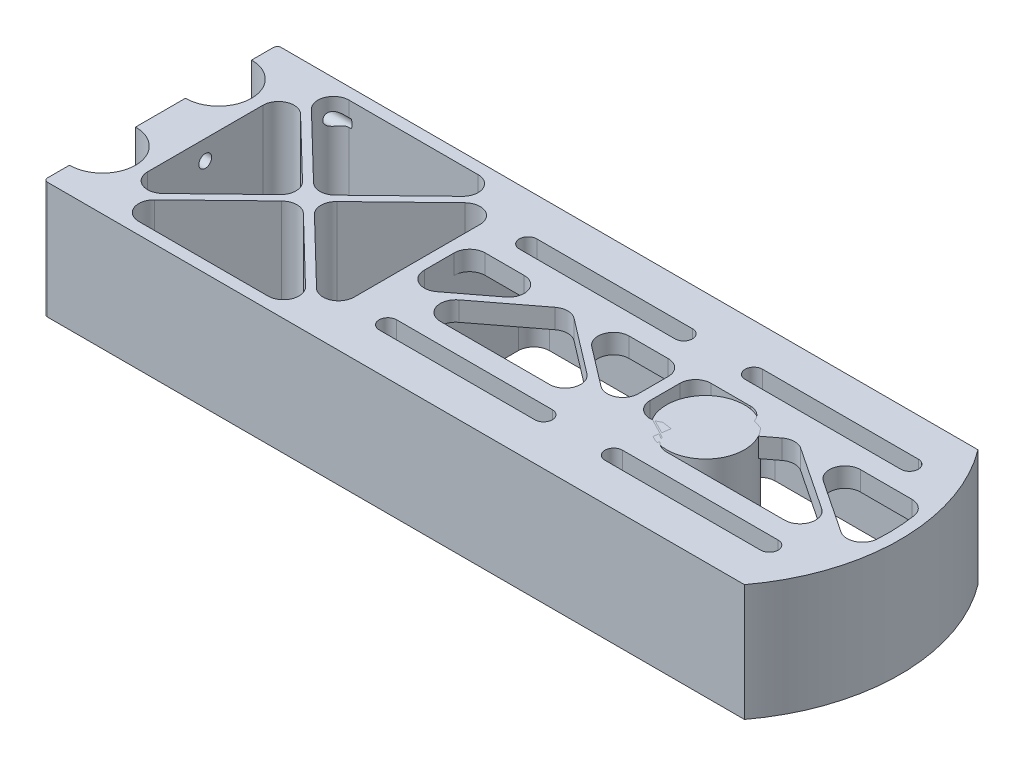
from build123d import *

# Parameters (mm, degrees)
EXTRUDE_1_DEPTH      = 30
CUT_EXTRUDE_1_DEPTH  = 31
TEMP_R               = 10
EXTRUDE_2_DEPTH      = 30
EXTRUDE_3_DEPTH      = 5
EXTRUDE_4_DEPTH      = 30
SKETCH_6_W           = 3
SKETCH_6_H           = 54
EXTRUDE_5_DEPTH      = 30
EXTRUDE_6_DEPTH      = 30
SKETCH_9_W           = 3
SKETCH_9_H           = 54
EXTRUDE_8_DEPTH      = 25
EXTRUDE_8_DEPTH_BACK = 5
EXTRUDE_7_DEPTH      = 5
FILLET_1_R           = 4
FILLET_2_R           = 4
FILLET_3_R           = 4
EXTRUDE_9_DEPTH      = 5
CUT_EXTRUDE_4_DEPTH  = 31
EXTRUDE_10_DEPTH     = 30
FILLET_4_R           = 4
M4X0_71_AT_2_COUNT   = 2
M4X0_71_AT_2_PITCH   = 25.75
M4X0_71_AT_3_COUNT   = 2
M4X0_71_AT_3_PITCH   = 51.5
M4X0_71_AT_4_COUNT   = 2
M4X0_71_AT_4_PITCH   = 55.247171873
M4X0_71_AT_5_COUNT   = 2
M4X0_71_AT_5_PITCH   = 32.60463924
M4X0_71_AT_6_COUNT   = 2
M4X0_71_AT_6_PITCH   = 20
FILLET_5_R           = 1


with BuildPart() as part:
    # Эскиз1 → Бобышка-Вытянуть1 (new body)
    with BuildSketch(Plane(origin=(0, 0, 0), x_dir=(1, 0, 0), z_dir=(0, 1, 0))):
        with BuildLine():
            Line((0, 60), (180, 60))
            ThreePointArc((180, 60), (190, 30), (180, 0))
            Line((180, 0), (0, 0))
            Line((0, 0), (0, 8))
            ThreePointArc((0, 8), (7.1, 15.1), (0, 22.2))
            Line((0, 22.2), (0, 37.8))
            ThreePointArc((0, 37.8), (7.1, 44.9), (0, 52))
            Line((0, 52), (0, 60))
        make_face()
    extrude(amount=EXTRUDE_1_DEPTH)

    # Эскиз2 → Вырез-Вытянуть1 (cut, through all)
    with BuildSketch(Plane(origin=(0, 30, 0), x_dir=(1, 0, 0), z_dir=(0, 1, 0))):
        with BuildLine():
            Line((3, 3), (178.470768123, 3))
            ThreePointArc((178.470768123, 3), (187, 30), (178.470768123, 57))
            Line((178.470768123, 57), (3, 57))
            Line((3, 57), (3, 54.544169223))
            ThreePointArc((3, 54.544169223), (10.1, 44.9), (3, 35.255830777))
            Line((3, 35.255830777), (3, 24.744169223))
            ThreePointArc((3, 24.744169223), (10.1, 15.1), (3, 5.455830777))
            Line((3, 5.455830777), (3, 3))
        make_face()
    extrude(amount=-CUT_EXTRUDE_1_DEPTH, mode=Mode.SUBTRACT)

    # Эскиз3 → Бобышка-Вытянуть3 (add)
    with BuildSketch(Plane(origin=(0, 30, 0), x_dir=(1, 0, 0), z_dir=(0, 1, 0))):
        with BuildLine():
            Line((178.470768123, 57), (68.916586692, 57))
            Line((68.916586692, 57), (68.916586692, 40.5))
            Line((68.916586692, 40.5), (185.812116301, 40.5))
            ThreePointArc((185.812116301, 40.5), (182.941397878, 49.105924428), (178.470768123, 57))
        make_face()
        with BuildLine():
            Line((116.416586692, 43.5), (76.416586692, 43.5))
            ThreePointArc((76.416586692, 43.5), (71.916586692, 48), (76.416586692, 52.5))
            Line((76.416586692, 52.5), (116.416586692, 52.5))
            ThreePointArc((116.416586692, 52.5), (120.916586692, 48), (116.416586692, 43.5))
        make_face(mode=Mode.SUBTRACT)
        with BuildLine():
            ThreePointArc((174.416586692, 52.5), (178.916586692, 48), (174.416586692, 43.5))
            Line((174.416586692, 43.5), (134.416586692, 43.5))
            ThreePointArc((134.416586692, 43.5), (129.916586692, 48), (134.416586692, 52.5))
            Line((134.416586692, 52.5), (174.416586692, 52.5))
        make_face(mode=Mode.SUBTRACT)
        with BuildLine():
            ThreePointArc((178.470768123, 3), (182.941397878, 10.894075572), (185.812116301, 19.5))
            Line((185.812116301, 19.5), (68.916586692, 19.5))
            Line((68.916586692, 19.5), (68.916586692, 3))
            Line((68.916586692, 3), (178.470768123, 3))
        make_face()
        with BuildLine():
            ThreePointArc((76.416586692, 7.5), (71.916586692, 12), (76.416586692, 16.5))
            Line((76.416586692, 16.5), (116.416586692, 16.5))
            ThreePointArc((116.416586692, 16.5), (120.916586692, 12), (116.416586692, 7.5))
            Line((116.416586692, 7.5), (76.416586692, 7.5))
        make_face(mode=Mode.SUBTRACT)
        with BuildLine():
            Line((134.416586692, 16.5), (174.416586692, 16.5))
            ThreePointArc((174.416586692, 16.5), (178.916586692, 12), (174.416586692, 7.5))
            Line((174.416586692, 7.5), (134.416586692, 7.5))
            ThreePointArc((134.416586692, 7.5), (129.916586692, 12), (134.416586692, 16.5))
        make_face(mode=Mode.SUBTRACT)
    extrude(amount=-EXTRUDE_3_DEPTH)

    # Эскиз4 → Бобышка-Вытянуть4 (add, through all)
    with BuildSketch(Plane(origin=(0, 30, 0), x_dir=(1, 0, 0), z_dir=(0, 1, 0))):
        with BuildLine():
            Line((10.1, 57), (3, 57))
            Line((3, 57), (3, 54.544169223))
            ThreePointArc((3, 54.544169223), (8.133572401, 50.887904475), (10.1, 44.9))
            Line((10.1, 44.9), (10.1, 57))
        make_face()
        with BuildLine():
            Line((10.1, 15.099999916), (10.1, 44.9))
            ThreePointArc((10.1, 44.9), (8.133572401, 38.912095525), (3, 35.255830777))
            Line((3, 35.255830777), (3, 24.744169223))
            ThreePointArc((3, 24.744169223), (8.133572426, 21.087904441), (10.1, 15.099999916))
        make_face()
        with BuildLine():
            Line((10.1, 3), (10.1, 15.099999916))
            ThreePointArc((10.1, 15.099999916), (8.133572376, 9.112095491), (3, 5.455830777))
            Line((3, 5.455830777), (3, 3))
            Line((3, 3), (10.1, 3))
        make_face()
    extrude(amount=-EXTRUDE_4_DEPTH)

    # Эскиз6 → Бобышка-Вытянуть5 (add, through all)
    with BuildSketch(Plane(origin=(0, 30, 0), x_dir=(1, 0, 0), z_dir=(0, 1, 0))):
        with Locations((67.416586692, 30)):
            Rectangle(SKETCH_6_W, SKETCH_6_H)
    extrude(amount=-EXTRUDE_5_DEPTH)

    # Эскиз7 → Бобышка-Вытянуть6 (add, through all)
    with BuildSketch(Plane(origin=(0, 30, 0), x_dir=(1, 0, 0), z_dir=(0, 1, 0))):
        Polygon((10.1, 55.608609353), (36.57009563, 30), (10.1, 4.391390647), (10.1, 3), (11.538197716, 3), (38.008293346, 28.608609353), (64.478388976, 3), (65.916586692, 3), (65.916586692, 4.391390647), (39.446491062, 30), (65.916586692, 55.608609353), (65.916586692, 57), (64.478388976, 57), (38.008293346, 31.391390647), (11.538197716, 57), (10.1, 57), align=None)
    extrude(amount=-EXTRUDE_6_DEPTH)

    # Эскиз9 → Бобышка-Вытянуть8 (add, two sides)
    with BuildSketch(Plane.XZ.offset(-25)) as extrude_8_sk:
        with Locations((125.416586692, -30)):
            Rectangle(SKETCH_9_W, SKETCH_9_H)
    extrude(amount=EXTRUDE_8_DEPTH)
    extrude(extrude_8_sk.sketch, amount=-EXTRUDE_8_DEPTH_BACK)

    # Эскиз8 → Бобышка-Вытянуть7 (add)
    with BuildSketch(Plane(origin=(0, 30, 0), x_dir=(1, 0, 0), z_dir=(0, 1, 0))):
        Polygon((70.564267671, 19.5), (96.416586692, 39.241770889), (122.268905713, 19.5), (123.916586692, 19.5), (123.916586692, 20.758229111), (98.064267671, 40.5), (94.768905713, 40.5), (68.916586692, 20.758229111), (68.916586692, 19.5), align=None)
        with BuildLine():
            Line((128.569887735, 19.5), (154.477979009, 39.178204914))
            Line((154.477979009, 39.178204914), (184.008770478, 19.5))
            Line((184.008770478, 19.5), (185.812116301, 19.5))
            ThreePointArc((185.812116301, 19.5), (185.929117822, 20.024222532), (186.040120933, 20.549747915))
            Line((186.040120933, 20.549747915), (156.101072293, 40.5))
            Line((156.101072293, 40.5), (152.911636662, 40.5))
            Line((152.911636662, 40.5), (126.916586692, 20.755746568))
            Line((126.916586692, 20.755746568), (126.916586692, 19.5))
            Line((126.916586692, 19.5), (128.569887735, 19.5))
        make_face()
    extrude(amount=-EXTRUDE_7_DEPTH)

    # Скругление1
    fillet_1_edges = [part.edges().sort_by_distance(p)[0] for p in [
        (36.57009563, 15, -30),
        (11.538197716, 15, -57),
        (38.008293346, 15, -31.391390647),
        (64.478388976, 15, -57),
        (65.916586692, 15, -55.608609353),
        (39.446491062, 15, -30),
        (65.916586692, 15, -4.391390647),
        (64.478388976, 15, -3),
        (38.008293346, 15, -28.608609353),
        (11.538197716, 15, -3),
    ]]
    fillet(fillet_1_edges, radius=FILLET_1_R)

    # Скругление2
    fillet_2_edges = [part.edges().sort_by_distance(p)[0] for p in [
        (68.916586692, 12.5, -57),
        (68.916586692, 12.5, -3),
        (123.916586692, 12.5, -57),
        (126.916586692, 12.5, -3),
        (123.916586692, 12.5, -3),
        (126.916586692, 12.5, -57),
        (178.470768123, 12.5, -57),
        (178.470768123, 12.5, -3),
    ]]
    fillet(fillet_2_edges, radius=FILLET_2_R)

    # Скругление3
    fillet_3_edges = [part.edges().sort_by_distance(p)[0] for p in [
        (123.916586692, 27.5, -40.5),
        (126.916586692, 27.5, -40.5),
        (70.564267671, 27.5, -19.5),
        (68.916586692, 27.5, -20.758229111),
        (94.768905713, 27.5, -40.5),
        (98.064267671, 27.5, -40.5),
        (123.916586692, 27.5, -20.758229111),
        (122.268905713, 27.5, -19.5),
        (96.416586692, 27.5, -39.241770889),
        (128.569887735, 27.5, -19.5),
        (126.916586692, 27.5, -20.755746568),
        (152.911636662, 27.5, -40.5),
        (156.101072293, 27.5, -40.5),
        (186.040120933, 27.5, -20.549747915),
        (184.008770478, 27.5, -19.5),
        (154.477979009, 27.5, -39.178204914),
        (68.916586692, 27.5, -40.5),
        (185.812116301, 27.5, -40.5),
    ]]
    fillet(fillet_3_edges, radius=FILLET_3_R)

    # Эскиз10 → Бобышка-Вытянуть9 (add)
    with BuildSketch(Plane(origin=(0, 30, 0), x_dir=(1, 0, 0), z_dir=(0, 1, 0))):
        with BuildLine():
            Line((76.416586692, 52.5), (116.416586692, 52.5))
            ThreePointArc((116.416586692, 52.5), (120.916586692, 48), (116.416586692, 43.5))
            Line((116.416586692, 43.5), (76.416586692, 43.5))
            ThreePointArc((76.416586692, 43.5), (71.916586692, 48), (76.416586692, 52.5))
        make_face()
        with BuildLine():
            Line((116.416586692, 50.25), (76.416586692, 50.25))
            ThreePointArc((76.416586692, 50.25), (74.166586692, 48), (76.416586692, 45.75))
            Line((76.416586692, 45.75), (116.416586692, 45.75))
            ThreePointArc((116.416586692, 45.75), (118.666586692, 48), (116.416586692, 50.25))
        make_face(mode=Mode.SUBTRACT)
        with BuildLine():
            Line((174.416586692, 52.5), (134.416586692, 52.5))
            ThreePointArc((134.416586692, 52.5), (129.916586692, 48), (134.416586692, 43.5))
            Line((134.416586692, 43.5), (174.416586692, 43.5))
            ThreePointArc((174.416586692, 43.5), (178.916586692, 48), (174.416586692, 52.5))
        make_face()
        with BuildLine():
            Line((174.416586692, 45.75), (134.416586692, 45.75))
            ThreePointArc((134.416586692, 45.75), (132.166586692, 48), (134.416586692, 50.25))
            Line((134.416586692, 50.25), (174.416586692, 50.25))
            ThreePointArc((174.416586692, 50.25), (176.666586692, 48), (174.416586692, 45.75))
        make_face(mode=Mode.SUBTRACT)
        with BuildLine():
            Line((76.416586692, 16.5), (116.416586692, 16.5))
            ThreePointArc((116.416586692, 16.5), (120.916586692, 12), (116.416586692, 7.5))
            Line((116.416586692, 7.5), (76.416586692, 7.5))
            ThreePointArc((76.416586692, 7.5), (71.916586692, 12), (76.416586692, 16.5))
        make_face()
        with BuildLine():
            Line((76.416586692, 9.75), (116.416586692, 9.75))
            ThreePointArc((116.416586692, 9.75), (118.666586692, 12), (116.416586692, 14.25))
            Line((116.416586692, 14.25), (76.416586692, 14.25))
            ThreePointArc((76.416586692, 14.25), (74.166586692, 12), (76.416586692, 9.75))
        make_face(mode=Mode.SUBTRACT)
        with BuildLine():
            Line((174.416586692, 16.5), (134.416586692, 16.5))
            ThreePointArc((134.416586692, 16.5), (129.916586692, 12), (134.416586692, 7.5))
            Line((134.416586692, 7.5), (174.416586692, 7.5))
            ThreePointArc((174.416586692, 7.5), (178.916586692, 12), (174.416586692, 16.5))
        make_face()
        with BuildLine():
            Line((174.416586692, 14.25), (134.416586692, 14.25))
            ThreePointArc((134.416586692, 14.25), (132.166586692, 12), (134.416586692, 9.75))
            Line((134.416586692, 9.75), (174.416586692, 9.75))
            ThreePointArc((174.416586692, 9.75), (176.666586692, 12), (174.416586692, 14.25))
        make_face(mode=Mode.SUBTRACT)
    extrude(amount=-EXTRUDE_9_DEPTH)

    # Эскиз16 → Вырез-Вытянуть4 (cut, through all)
    with BuildSketch(Plane(origin=(0, 30, 0), x_dir=(1, 0, 0), z_dir=(0, 1, 0))):
        with BuildLine():
            Line((0, 8), (0, 6.6))
            ThreePointArc((0, 6.6), (8.5, 15.1), (0, 23.6))
            Line((0, 23.6), (0, 22.2))
            ThreePointArc((0, 22.2), (7.1, 15.1), (0, 8))
        make_face()
        with BuildLine():
            Line((0, 37.8), (0, 36.4))
            ThreePointArc((0, 36.4), (8.5, 44.9), (0, 53.4))
            Line((0, 53.4), (0, 52))
            ThreePointArc((0, 52), (7.1, 44.9), (0, 37.8))
        make_face()
    extrude(amount=-CUT_EXTRUDE_4_DEPTH, mode=Mode.SUBTRACT)

    # Эскиз17 → Бобышка-Вытянуть10 (add, through all)
    with BuildSketch(Plane(origin=(0, 30, 0), x_dir=(1, 0, 0), z_dir=(0, 1, 0))):
        Polygon((11.5, 54.254173253), (11.5, 5.745826747), (10.1, 4.391390647), (10.1, 55.608609353), align=None)
    extrude(amount=-EXTRUDE_10_DEPTH)

    # Скругление4
    fillet_4_edges = [part.edges().sort_by_distance(p)[0] for p in [
        (11.5, 15, -54.254173253),
        (11.5, 15, -5.745826747),
    ]]
    fillet(fillet_4_edges, radius=FILLET_4_R)

    # Эскиз14 → Отверстие обработанное метчиком M4x0.71 (revolve, cut)
    with BuildSketch(Plane(origin=(0, 25, -55.75), x_dir=(0, 0, 1), z_dir=(0, 1, 0))):
        Polygon((0, 0), (0, 22.991420021), (1.65, 22), (1.65, 0), align=None)
    m4x0_71 = revolve(axis=Axis((-6.35, 25, -55.75), (1, 0, 0)), mode=Mode.SUBTRACT)

    # Отверстие обработанное метчиком M4x0.71 at 2: Отверстие обработанное метчиком M4x0.71 ×2
    with Locations(*[(0, 0, i * M4X0_71_AT_2_PITCH) for i in range(1, M4X0_71_AT_2_COUNT)]):
        add(m4x0_71, mode=Mode.SUBTRACT)

    # Отверстие обработанное метчиком M4x0.71 at 3: Отверстие обработанное метчиком M4x0.71 ×2
    with Locations(*[(0, 0, i * M4X0_71_AT_3_PITCH) for i in range(1, M4X0_71_AT_3_COUNT)]):
        add(m4x0_71, mode=Mode.SUBTRACT)

    # Отверстие обработанное метчиком M4x0.71 at 4: Отверстие обработанное метчиком M4x0.71 ×2
    with Locations(*[Vector(0, -0.362009481, 0.932174413) * (i * M4X0_71_AT_4_PITCH) for i in range(1, M4X0_71_AT_4_COUNT)]):
        add(m4x0_71, mode=Mode.SUBTRACT)

    # Отверстие обработанное метчиком M4x0.71 at 5: Отверстие обработанное метчиком M4x0.71 ×2
    with Locations(*[Vector(0, -0.613409639, 0.789764911) * (i * M4X0_71_AT_5_PITCH) for i in range(1, M4X0_71_AT_5_COUNT)]):
        add(m4x0_71, mode=Mode.SUBTRACT)

    # Отверстие обработанное метчиком M4x0.71 at 6: Отверстие обработанное метчиком M4x0.71 ×2
    with Locations(*[(0, -i * M4X0_71_AT_6_PITCH, 0) for i in range(1, M4X0_71_AT_6_COUNT)]):
        add(m4x0_71, mode=Mode.SUBTRACT)

    # Скругление5
    fillet_5_edges = [part.edges().sort_by_distance(p)[0] for p in [
        (0, 15, 0),
        (0, 15, -60),
    ]]
    fillet(fillet_5_edges, radius=FILLET_5_R)


with BuildPart() as body_2:
    # Temp → Бобышка-Вытянуть2 (new body)
    with BuildSketch(Plane(origin=(0, 30, 0), x_dir=(1, 0, 0), z_dir=(0, 1, 0))):
        with Locations((140, 30)):
            Circle(TEMP_R)
    extrude(amount=-EXTRUDE_2_DEPTH)


solid = Compound([part.part, body_2.part])
